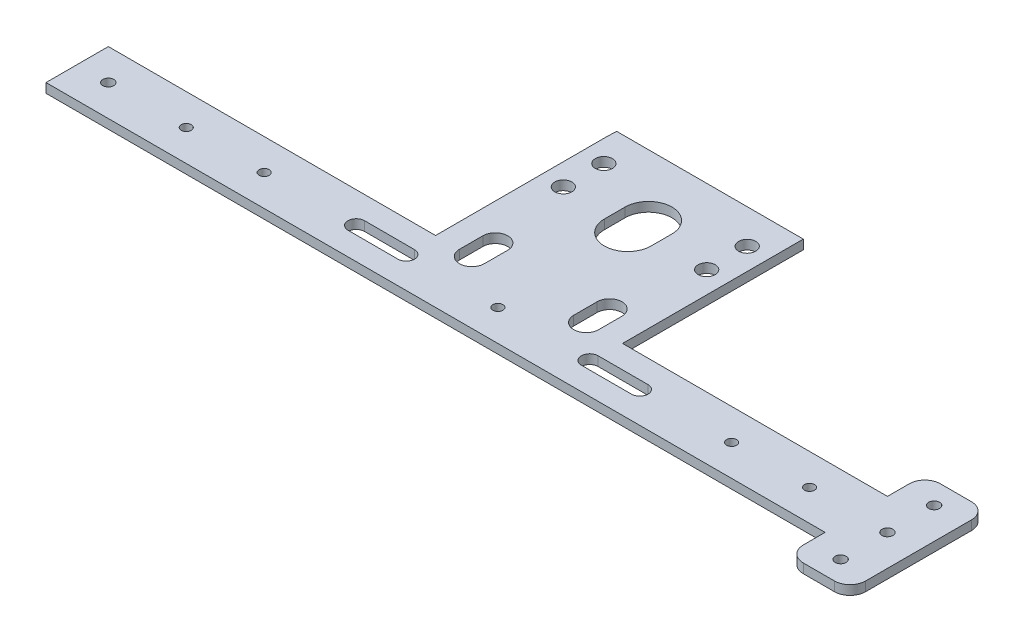
from build123d import *

# Parameters (mm, degrees)
SKETCH_1_W          = 270
SKETCH_1_H          = 100
EXTRUDE_1_DEPTH     = 3
SKETCH_2_R          = 1.6
SKETCH_2_R_2        = 1.75
CUT_EXTRUDE_1_DEPTH = 3
CUT_EXTRUDE_2_DEPTH = 10
SKETCH_5_R          = 2.75
CUT_EXTRUDE_3_DEPTH = 10
SKETCH_6_W          = 60
SKETCH_6_H          = 22
CUT_EXTRUDE_4_DEPTH = 10
EXTRUDE_2_DEPTH     = 3
EXTRUDE_3_DEPTH     = 3
EXTRUDE_4_DEPTH     = 3
EXTRUDE_6_DEPTH     = 3
EXTRUDE_7_DEPTH     = 3
SKETCH_13_W         = 0.825922264
SKETCH_13_H         = 3.102588021
EXTRUDE_8_DEPTH     = 3
EXTRUDE_9_DEPTH     = 3
EXTRUDE_10_DEPTH    = 3
SKETCH_16_W         = 8
SKETCH_16_H         = 5.433103104
EXTRUDE_11_DEPTH    = 3
EXTRUDE_12_DEPTH    = 3
SKETCH_18_W         = 1.102641526
SKETCH_18_H         = 13.538509376
EXTRUDE_13_DEPTH    = 3
EXTRUDE_14_DEPTH    = 3
EXTRUDE_15_DEPTH    = 3
EXTRUDE_16_DEPTH    = 3
EXTRUDE_17_DEPTH    = 3
CUT_EXTRUDE_5_DEPTH = 3
SKETCH_24_W         = 20
SKETCH_24_H         = 12
EXTRUDE_18_DEPTH    = 3
SKETCH_25_W         = 20
SKETCH_25_H         = 12
EXTRUDE_19_DEPTH    = 3
SKETCH_26_R         = 1.75
CUT_EXTRUDE_6_DEPTH = 4
FILLET_1_R          = 5


with BuildPart() as part:
    # 草图1 → 凸台-拉伸1 (new body)
    with BuildSketch(Plane(origin=(0, 0, 0), x_dir=(1, 0, 0), z_dir=(0, 1, 0))):
        Rectangle(SKETCH_1_W, SKETCH_1_H)
    extrude(amount=EXTRUDE_1_DEPTH)

    # 草图2 → 切除-拉伸1 (cut)
    with BuildSketch(Plane(origin=(0, 3, 0), x_dir=(1, 0, 0), z_dir=(0, 1, 0))):
        with Locations((-125, 40)):
            Circle(SKETCH_2_R)
        with Locations((-125, 0)):
            Circle(SKETCH_2_R)
        with Locations((125, 0)):
            Circle(SKETCH_2_R)
        with Locations((125, 40)):
            Circle(SKETCH_2_R)
        with Locations((-125, -40)):
            Circle(SKETCH_2_R_2)
        with Locations((-100, -40)):
            Circle(SKETCH_2_R)
        with Locations((-75, -40)):
            Circle(SKETCH_2_R)
        with Locations((0, -40)):
            Circle(SKETCH_2_R)
        with Locations((75, -40)):
            Circle(SKETCH_2_R)
        with Locations((100, -40)):
            Circle(SKETCH_2_R)
        with Locations((125, -40)):
            Circle(SKETCH_2_R_2)
    extrude(amount=-CUT_EXTRUDE_1_DEPTH, mode=Mode.SUBTRACT)

    # 草图4 → 切除-拉伸2 (cut)
    with BuildSketch(Plane(origin=(0, 3, 0), x_dir=(1, 0, 0), z_dir=(0, 1, 0))):
        with BuildLine():
            Line((102.5, -30), (102.5, -23.333333333))
            ThreePointArc((102.5, -23.333333333), (110, -15.833333333), (117.5, -23.333333333))
            Line((117.5, -23.333333333), (117.5, -30))
            ThreePointArc((117.5, -30), (110, -37.5), (102.5, -30))
        make_face()
        with BuildLine():
            Line((102.5, 1.666666667), (102.5, 8.333333333))
            ThreePointArc((102.5, 8.333333333), (110, 15.833333333), (117.5, 8.333333333))
            Line((117.5, 8.333333333), (117.5, 1.666666667))
            ThreePointArc((117.5, 1.666666667), (110, -5.833333333), (102.5, 1.666666667))
        make_face()
        with BuildLine():
            Line((102.5, 28.333333333), (102.5, 35))
            ThreePointArc((102.5, 35), (110, 42.5), (117.5, 35))
            Line((117.5, 35), (117.5, 28.333333333))
            ThreePointArc((117.5, 28.333333333), (110, 20.833333333), (102.5, 28.333333333))
        make_face()
        with BuildLine():
            Line((87.666666667, -30), (87.666666667, -22.5))
            ThreePointArc((87.666666667, -22.5), (91.666666667, -18.5), (95.666666667, -22.5))
            Line((95.666666667, -22.5), (95.666666667, -30))
            ThreePointArc((95.666666667, -30), (91.666666667, -34), (87.666666667, -30))
        make_face()
        with BuildLine():
            Line((87.666666667, -10.5), (87.666666667, -6.5))
            ThreePointArc((87.666666667, -6.5), (91.666666667, -2.5), (95.666666667, -6.5))
            Line((95.666666667, -6.5), (95.666666667, -10.5))
            ThreePointArc((95.666666667, -10.5), (91.666666667, -14.5), (87.666666667, -10.5))
        make_face()
        with BuildLine():
            Line((87.666666667, 8.5), (87.666666667, 12.5))
            ThreePointArc((87.666666667, 12.5), (91.666666667, 16.5), (95.666666667, 12.5))
            Line((95.666666667, 12.5), (95.666666667, 8.5))
            ThreePointArc((95.666666667, 8.5), (91.666666667, 4.5), (87.666666667, 8.5))
        make_face()
        with BuildLine():
            Line((95.666666667, 35), (95.666666667, 27.5))
            ThreePointArc((95.666666667, 27.5), (91.666666667, 23.5), (87.666666667, 27.5))
            Line((87.666666667, 27.5), (87.666666667, 35))
            ThreePointArc((87.666666667, 35), (91.666666667, 39), (95.666666667, 35))
        make_face()
        with BuildLine():
            Line((65.833333333, 1.666666667), (65.833333333, 8.333333333))
            ThreePointArc((65.833333333, 8.333333333), (73.333333333, 15.833333333), (80.833333333, 8.333333333))
            Line((80.833333333, 8.333333333), (80.833333333, 1.666666667))
            ThreePointArc((80.833333333, 1.666666667), (73.333333333, -5.833333333), (65.833333333, 1.666666667))
        make_face()
        with BuildLine():
            Line((65.833333333, 28.333333333), (65.833333333, 35))
            ThreePointArc((65.833333333, 35), (73.333333333, 42.5), (80.833333333, 35))
            Line((80.833333333, 35), (80.833333333, 28.333333333))
            ThreePointArc((80.833333333, 28.333333333), (73.333333333, 20.833333333), (65.833333333, 28.333333333))
        make_face()
        with BuildLine():
            Line((51, -30), (51, -22.5))
            ThreePointArc((51, -22.5), (55, -18.5), (59, -22.5))
            Line((59, -22.5), (59, -30))
            ThreePointArc((59, -30), (55, -34), (51, -30))
        make_face()
        with BuildLine():
            Line((51, -10.5), (51, -6.5))
            ThreePointArc((51, -6.5), (55, -2.5), (59, -6.5))
            Line((59, -6.5), (59, -10.5))
            ThreePointArc((59, -10.5), (55, -14.5), (51, -10.5))
        make_face()
        with BuildLine():
            Line((51, 8.5), (51, 12.5))
            ThreePointArc((51, 12.5), (55, 16.5), (59, 12.5))
            Line((59, 12.5), (59, 8.5))
            ThreePointArc((59, 8.5), (55, 4.5), (51, 8.5))
        make_face()
        with BuildLine():
            Line((59, 35), (59, 27.5))
            ThreePointArc((59, 27.5), (55, 23.5), (51, 27.5))
            Line((51, 27.5), (51, 35))
            ThreePointArc((51, 35), (55, 39), (59, 35))
        make_face()
        with BuildLine():
            Line((29.166666667, -30), (29.166666667, -23.333333333))
            ThreePointArc((29.166666667, -23.333333333), (36.666666667, -15.833333333), (44.166666667, -23.333333333))
            Line((44.166666667, -23.333333333), (44.166666667, -30))
            ThreePointArc((44.166666667, -30), (36.666666667, -37.5), (29.166666667, -30))
        make_face()
        with BuildLine():
            Line((29.166666667, 1.666666667), (29.166666667, 8.333333333))
            ThreePointArc((29.166666667, 8.333333333), (36.666666667, 15.833333333), (44.166666667, 8.333333333))
            Line((44.166666667, 8.333333333), (44.166666667, 1.666666667))
            ThreePointArc((44.166666667, 1.666666667), (36.666666667, -5.833333333), (29.166666667, 1.666666667))
        make_face()
        with BuildLine():
            Line((29.166666667, 28.333333333), (29.166666667, 35))
            ThreePointArc((29.166666667, 35), (36.666666667, 42.5), (44.166666667, 35))
            Line((44.166666667, 35), (44.166666667, 28.333333333))
            ThreePointArc((44.166666667, 28.333333333), (36.666666667, 20.833333333), (29.166666667, 28.333333333))
        make_face()
        with BuildLine():
            Line((14.333333333, -30), (14.333333333, -22.5))
            ThreePointArc((14.333333333, -22.5), (18.333333333, -18.5), (22.333333333, -22.5))
            Line((22.333333333, -22.5), (22.333333333, -30))
            ThreePointArc((22.333333333, -30), (18.333333333, -34), (14.333333333, -30))
        make_face()
        with BuildLine():
            Line((22.333333333, 35), (22.333333333, 27.5))
            ThreePointArc((22.333333333, 27.5), (18.333333333, 23.5), (14.333333333, 27.5))
            Line((14.333333333, 27.5), (14.333333333, 35))
            ThreePointArc((14.333333333, 35), (18.333333333, 39), (22.333333333, 35))
        make_face()
        with BuildLine():
            Line((-7.5, 1.666666667), (-7.5, 8.333333333))
            ThreePointArc((-7.5, 8.333333333), (0, 15.833333333), (7.5, 8.333333333))
            Line((7.5, 8.333333333), (7.5, 1.666666667))
            ThreePointArc((7.5, 1.666666667), (0, -5.833333333), (-7.5, 1.666666667))
        make_face()
        with BuildLine():
            Line((-7.5, 28.333333333), (-7.5, 35))
            ThreePointArc((-7.5, 35), (0, 42.5), (7.5, 35))
            Line((7.5, 35), (7.5, 28.333333333))
            ThreePointArc((7.5, 28.333333333), (0, 20.833333333), (-7.5, 28.333333333))
        make_face()
        with BuildLine():
            Line((-22.333333333, -30), (-22.333333333, -22.5))
            ThreePointArc((-22.333333333, -22.5), (-18.333333333, -18.5), (-14.333333333, -22.5))
            Line((-14.333333333, -22.5), (-14.333333333, -30))
            ThreePointArc((-14.333333333, -30), (-18.333333333, -34), (-22.333333333, -30))
        make_face()
        with BuildLine():
            Line((-14.333333333, 35), (-14.333333333, 27.5))
            ThreePointArc((-14.333333333, 27.5), (-18.333333333, 23.5), (-22.333333333, 27.5))
            Line((-22.333333333, 27.5), (-22.333333333, 35))
            ThreePointArc((-22.333333333, 35), (-18.333333333, 39), (-14.333333333, 35))
        make_face()
        with BuildLine():
            Line((-44.166666667, -30), (-44.166666667, -23.333333333))
            ThreePointArc((-44.166666667, -23.333333333), (-36.666666667, -15.833333333), (-29.166666667, -23.333333333))
            Line((-29.166666667, -23.333333333), (-29.166666667, -30))
            ThreePointArc((-29.166666667, -30), (-36.666666667, -37.5), (-44.166666667, -30))
        make_face()
        with BuildLine():
            Line((-44.166666667, 1.666666667), (-44.166666667, 8.333333333))
            ThreePointArc((-44.166666667, 8.333333333), (-36.666666667, 15.833333333), (-29.166666667, 8.333333333))
            Line((-29.166666667, 8.333333333), (-29.166666667, 1.666666667))
            ThreePointArc((-29.166666667, 1.666666667), (-36.666666667, -5.833333333), (-44.166666667, 1.666666667))
        make_face()
        with BuildLine():
            Line((-44.166666667, 28.333333333), (-44.166666667, 35))
            ThreePointArc((-44.166666667, 35), (-36.666666667, 42.5), (-29.166666667, 35))
            Line((-29.166666667, 35), (-29.166666667, 28.333333333))
            ThreePointArc((-29.166666667, 28.333333333), (-36.666666667, 20.833333333), (-44.166666667, 28.333333333))
        make_face()
        with BuildLine():
            Line((-59, -30), (-59, -22.5))
            ThreePointArc((-59, -22.5), (-55, -18.5), (-51, -22.5))
            Line((-51, -22.5), (-51, -30))
            ThreePointArc((-51, -30), (-55, -34), (-59, -30))
        make_face()
        with BuildLine():
            Line((-59, -10.5), (-59, -6.5))
            ThreePointArc((-59, -6.5), (-55, -2.5), (-51, -6.5))
            Line((-51, -6.5), (-51, -10.5))
            ThreePointArc((-51, -10.5), (-55, -14.5), (-59, -10.5))
        make_face()
        with BuildLine():
            Line((-59, 8.5), (-59, 12.5))
            ThreePointArc((-59, 12.5), (-55, 16.5), (-51, 12.5))
            Line((-51, 12.5), (-51, 8.5))
            ThreePointArc((-51, 8.5), (-55, 4.5), (-59, 8.5))
        make_face()
        with BuildLine():
            Line((-51, 35), (-51, 27.5))
            ThreePointArc((-51, 27.5), (-55, 23.5), (-59, 27.5))
            Line((-59, 27.5), (-59, 35))
            ThreePointArc((-59, 35), (-55, 39), (-51, 35))
        make_face()
        with BuildLine():
            Line((-80.833333333, 1.666666667), (-80.833333333, 8.333333333))
            ThreePointArc((-80.833333333, 8.333333333), (-73.333333333, 15.833333333), (-65.833333333, 8.333333333))
            Line((-65.833333333, 8.333333333), (-65.833333333, 1.666666667))
            ThreePointArc((-65.833333333, 1.666666667), (-73.333333333, -5.833333333), (-80.833333333, 1.666666667))
        make_face()
        with BuildLine():
            Line((-80.833333333, 28.333333333), (-80.833333333, 35))
            ThreePointArc((-80.833333333, 35), (-73.333333333, 42.5), (-65.833333333, 35))
            Line((-65.833333333, 35), (-65.833333333, 28.333333333))
            ThreePointArc((-65.833333333, 28.333333333), (-73.333333333, 20.833333333), (-80.833333333, 28.333333333))
        make_face()
        with BuildLine():
            Line((-95.666666667, -30), (-95.666666667, -22.5))
            ThreePointArc((-95.666666667, -22.5), (-91.666666667, -18.5), (-87.666666667, -22.5))
            Line((-87.666666667, -22.5), (-87.666666667, -30))
            ThreePointArc((-87.666666667, -30), (-91.666666667, -34), (-95.666666667, -30))
        make_face()
        with BuildLine():
            Line((-95.666666667, -10.5), (-95.666666667, -6.5))
            ThreePointArc((-95.666666667, -6.5), (-91.666666667, -2.5), (-87.666666667, -6.5))
            Line((-87.666666667, -6.5), (-87.666666667, -10.5))
            ThreePointArc((-87.666666667, -10.5), (-91.666666667, -14.5), (-95.666666667, -10.5))
        make_face()
        with BuildLine():
            Line((-95.666666667, 8.5), (-95.666666667, 12.5))
            ThreePointArc((-95.666666667, 12.5), (-91.666666667, 16.5), (-87.666666667, 12.5))
            Line((-87.666666667, 12.5), (-87.666666667, 8.5))
            ThreePointArc((-87.666666667, 8.5), (-91.666666667, 4.5), (-95.666666667, 8.5))
        make_face()
        with BuildLine():
            Line((-87.666666667, 35), (-87.666666667, 27.5))
            ThreePointArc((-87.666666667, 27.5), (-91.666666667, 23.5), (-95.666666667, 27.5))
            Line((-95.666666667, 27.5), (-95.666666667, 35))
            ThreePointArc((-95.666666667, 35), (-91.666666667, 39), (-87.666666667, 35))
        make_face()
        with BuildLine():
            Line((-102.5, -30), (-102.5, -23.333333333))
            ThreePointArc((-102.5, -23.333333333), (-110, -15.833333333), (-117.5, -23.333333333))
            Line((-117.5, -23.333333333), (-117.5, -30))
            ThreePointArc((-117.5, -30), (-110, -37.5), (-102.5, -30))
        make_face()
        with BuildLine():
            Line((-102.5, 1.666666667), (-102.5, 8.333333333))
            ThreePointArc((-102.5, 8.333333333), (-110, 15.833333333), (-117.5, 8.333333333))
            Line((-117.5, 8.333333333), (-117.5, 1.666666667))
            ThreePointArc((-117.5, 1.666666667), (-110, -5.833333333), (-102.5, 1.666666667))
        make_face()
        with BuildLine():
            Line((-102.5, 28.333333333), (-102.5, 35))
            ThreePointArc((-102.5, 35), (-110, 42.5), (-117.5, 35))
            Line((-117.5, 35), (-117.5, 28.333333333))
            ThreePointArc((-117.5, 28.333333333), (-110, 20.833333333), (-102.5, 28.333333333))
        make_face()
    extrude(amount=-CUT_EXTRUDE_2_DEPTH, mode=Mode.SUBTRACT)

    # 草图5 → 切除-拉伸3 (cut)
    with BuildSketch(Plane(origin=(0, 3, 0), x_dir=(1, 0, 0), z_dir=(0, 1, 0))):
        with Locations((23, 17)):
            Circle(SKETCH_5_R)
        with Locations((23, 4)):
            Circle(SKETCH_5_R)
        with Locations((-23, 17)):
            Circle(SKETCH_5_R)
        with Locations((-23, 4)):
            Circle(SKETCH_5_R)
    extrude(amount=-CUT_EXTRUDE_3_DEPTH, mode=Mode.SUBTRACT)

    # 草图6 → 切除-拉伸4 (cut)
    with BuildSketch(Plane.XZ):
        Polygon((-135, -50), (-30, -50), (-30, -28), (-30, 30), (-135, 30), align=None)
        with Locations((0, -39)):
            Rectangle(SKETCH_6_W, SKETCH_6_H)
        Polygon((30, -28), (30, -50), (135, -50), (135, 30), (30, 30), align=None)
    extrude(amount=-CUT_EXTRUDE_4_DEPTH, mode=Mode.SUBTRACT)

    # 草图8 → 凸台-拉伸2 (add)
    with BuildSketch(Plane(origin=(0, 3, 0), x_dir=(1, 0, 0), z_dir=(0, 1, 0))):
        with BuildLine():
            Line((117.5, -30), (102.5, -30))
            ThreePointArc((102.5, -30), (110, -37.5), (117.5, -30))
        make_face()
    extrude(amount=-EXTRUDE_2_DEPTH)

    # 草图9 → 凸台-拉伸3 (add)
    with BuildSketch(Plane(origin=(0, 3, 0), x_dir=(1, 0, 0), z_dir=(0, 1, 0))):
        with BuildLine():
            Line((95.666666667, -30), (87.666666667, -30))
            ThreePointArc((87.666666667, -30), (91.666666667, -34), (95.666666667, -30))
        make_face()
    extrude(amount=-EXTRUDE_3_DEPTH)

    # 草图10 → 凸台-拉伸4 (add)
    with BuildSketch(Plane(origin=(0, 3, 0), x_dir=(1, 0, 0), z_dir=(0, 1, 0))):
        with BuildLine():
            Line((59, -30), (51, -30))
            ThreePointArc((51, -30), (55, -34), (59, -30))
        make_face()
    extrude(amount=-EXTRUDE_4_DEPTH)

    # 草图11 → 凸台-拉伸6 (add)
    with BuildSketch(Plane(origin=(0, 3, 0), x_dir=(1, 0, 0), z_dir=(0, 1, 0))):
        with BuildLine():
            Line((44.166666667, -30), (30, -30))
            Line((30, -30), (30, -19.897411979))
            Line((30, -19.897411979), (28.752910613, -21.894285676))
            Line((28.752910613, -21.894285676), (29.166666667, -30))
            ThreePointArc((29.166666667, -30), (36.666666667, -37.5), (44.166666667, -30))
        make_face()
    extrude(amount=-EXTRUDE_6_DEPTH)

    # 草图12 → 凸台-拉伸7 (add)
    with BuildSketch(Plane(origin=(0, 3, 0), x_dir=(1, 0, 0), z_dir=(0, 1, 0))):
        Polygon((30, -1.769254688), (30, 11.769254688), (29.039963262, 10.134277789), (28.809927387, -1.769254688), align=None)
    extrude(amount=-EXTRUDE_7_DEPTH)

    # 草图13 → 凸台-拉伸8 (add)
    with BuildSketch(Plane(origin=(0, 3, 0), x_dir=(1, 0, 0), z_dir=(0, 1, 0))):
        with Locations((29.587038868, 26.448705989)):
            Rectangle(SKETCH_13_W, SKETCH_13_H)
    extrude(amount=-EXTRUDE_8_DEPTH)

    # 草图14 → 凸台-拉伸9 (add)
    with BuildSketch(Plane(origin=(0, 3, 0), x_dir=(1, 0, 0), z_dir=(0, 1, 0))):
        Polygon((22.333333333, 28), (14.333333333, 28), (14.17115612, 22.861418701), (22.333333333, 22.861418701), align=None)
    extrude(amount=-EXTRUDE_9_DEPTH)

    # 草图15 → 凸台-拉伸10 (add)
    with BuildSketch(Plane(origin=(0, 3, 0), x_dir=(1, 0, 0), z_dir=(0, 1, 0))):
        with BuildLine():
            Line((7.492588931, 28), (-7.492588931, 28))
            ThreePointArc((-7.492588931, 28), (0, 20.507411069), (7.492588931, 28))
        make_face()
    extrude(amount=-EXTRUDE_10_DEPTH)

    # 草图16 → 凸台-拉伸11 (add)
    with BuildSketch(Plane(origin=(0, 3, 0), x_dir=(1, 0, 0), z_dir=(0, 1, 0))):
        with Locations((-18.333333333, 25.283448448)):
            Rectangle(SKETCH_16_W, SKETCH_16_H)
    extrude(amount=-EXTRUDE_11_DEPTH)

    # 草图17 → 凸台-拉伸12 (add)
    with BuildSketch(Plane(origin=(0, 3, 0), x_dir=(1, 0, 0), z_dir=(0, 1, 0))):
        Polygon((-29.174077736, 28), (-29.890375981, 28), (-30, 24.897411979), (-29.174077736, 24.897411979), align=None)
    extrude(amount=-EXTRUDE_12_DEPTH)

    # 草图18 → 凸台-拉伸13 (add)
    with BuildSketch(Plane(origin=(0, 3, 0), x_dir=(1, 0, 0), z_dir=(0, 1, 0))):
        with Locations((-29.448679237, 5)):
            Rectangle(SKETCH_18_W, SKETCH_18_H)
    extrude(amount=-EXTRUDE_13_DEPTH)

    # 草图19 → 凸台-拉伸14 (add)
    with BuildSketch(Plane(origin=(0, 3, 0), x_dir=(1, 0, 0), z_dir=(0, 1, 0))):
        with BuildLine():
            Line((-44.166666667, -30), (-30, -30))
            Line((-30, -30), (-30, -19.897411979))
            Line((-30, -19.897411979), (-29.166666667, -19.897411979))
            Line((-29.166666667, -19.897411979), (-29.166666667, -30))
            ThreePointArc((-29.166666667, -30), (-36.666666667, -37.5), (-44.166666667, -30))
        make_face()
    extrude(amount=-EXTRUDE_14_DEPTH)

    # 草图20 → 凸台-拉伸15 (add)
    with BuildSketch(Plane(origin=(0, 3, 0), x_dir=(1, 0, 0), z_dir=(0, 1, 0))):
        with BuildLine():
            Line((-51, -30), (-59, -30))
            ThreePointArc((-59, -30), (-55, -34), (-51, -30))
        make_face()
    extrude(amount=-EXTRUDE_15_DEPTH)

    # 草图21 → 凸台-拉伸16 (add)
    with BuildSketch(Plane(origin=(0, 3, 0), x_dir=(1, 0, 0), z_dir=(0, 1, 0))):
        with BuildLine():
            Line((-87.666666667, -30), (-95.666666667, -30))
            ThreePointArc((-95.666666667, -30), (-91.666666667, -34), (-87.666666667, -30))
        make_face()
    extrude(amount=-EXTRUDE_16_DEPTH)

    # 草图22 → 凸台-拉伸17 (add)
    with BuildSketch(Plane(origin=(0, 3, 0), x_dir=(1, 0, 0), z_dir=(0, 1, 0))):
        with BuildLine():
            Line((-102.5, -30), (-117.5, -30))
            ThreePointArc((-117.5, -30), (-110, -37.5), (-102.5, -30))
        make_face()
    extrude(amount=-EXTRUDE_17_DEPTH)

    # 草图23 → 切除-拉伸5 (cut)
    with BuildSketch(Plane(origin=(0, 3, 0), x_dir=(1, 0, 0), z_dir=(0, 1, 0))):
        with BuildLine():
            Line((45.522678084, -42.658423831), (29.477321916, -42.658423831))
            ThreePointArc((29.477321916, -42.658423831), (26.818898085, -40), (29.477321916, -37.341576169))
            Line((29.477321916, -37.341576169), (45.522678084, -37.341576169))
            ThreePointArc((45.522678084, -37.341576169), (48.181101915, -40), (45.522678084, -42.658423831))
        make_face()
        with BuildLine():
            Line((-45.512315013, -42.594451897), (-29.466974692, -42.617002609))
            ThreePointArc((-29.466974692, -42.617002609), (-26.804817243, -39.962317646), (-29.459502206, -37.300160198))
            Line((-29.459502206, -37.300160198), (-45.504842527, -37.277609485))
            ThreePointArc((-45.504842527, -37.277609485), (-48.166999976, -39.932294448), (-45.512315013, -42.594451897))
        make_face()
    extrude(amount=-CUT_EXTRUDE_5_DEPTH, mode=Mode.SUBTRACT)

    # 草图24 → 凸台-拉伸18 (add)
    with BuildSketch(Plane.XZ):
        with Locations((125, 56)):
            Rectangle(SKETCH_24_W, SKETCH_24_H)
    extrude(amount=-EXTRUDE_18_DEPTH)

    # 草图25 → 凸台-拉伸19 (add)
    with BuildSketch(Plane.XZ):
        with Locations((125, 24)):
            Rectangle(SKETCH_25_W, SKETCH_25_H)
    extrude(amount=-EXTRUDE_19_DEPTH)

    # 草图26 → 切除-拉伸6 (cut, through all)
    with BuildSketch(Plane(origin=(0, 3, 0), x_dir=(1, 0, 0), z_dir=(0, 1, 0))):
        with Locations((125, -55)):
            Circle(SKETCH_26_R)
        with Locations((125, -25)):
            Circle(SKETCH_26_R)
    extrude(amount=-CUT_EXTRUDE_6_DEPTH, mode=Mode.SUBTRACT)

    # 圆角1
    fillet_1_edges = [part.edges().sort_by_distance(p)[0] for p in [
        (135, 1.5, 62),
        (115, 1.5, 62),
        (115, 1.5, 18),
        (135, 1.5, 18),
    ]]
    fillet(fillet_1_edges, radius=FILLET_1_R)


solid = part.part
